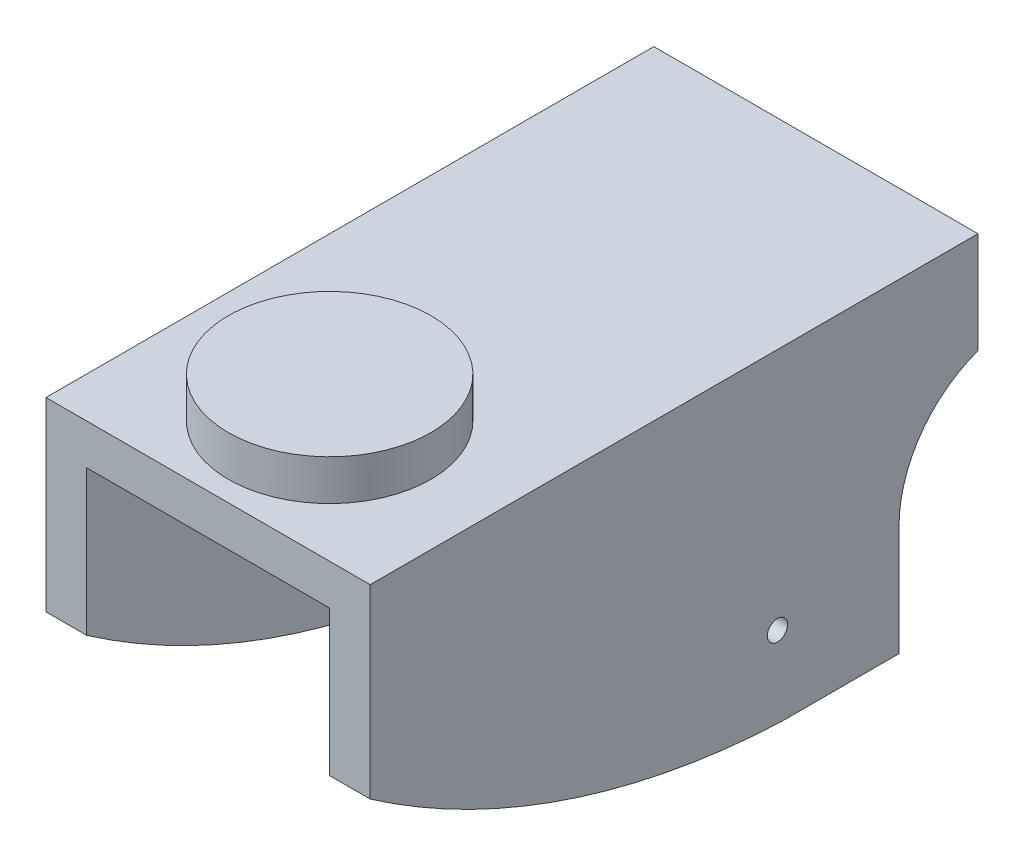
from build123d import *

# Parameters (mm, degrees)
BOSS_EXTRUDE1_DEPTH     = 20.32
SHELL1_T                = -2.54
SKETCH3_R               = 6.35
BOSS_EXTRUDE2_DEPTH     = 2.54
SKETCH5_R               = 0.635
CUT_EXTRUDE2_DEPTH      = 1
CUT_EXTRUDE2_DEPTH_BACK = 21.32


with BuildPart() as part:
    # Sketch2 → Boss-Extrude1 (new body)
    with BuildSketch(Plane(origin=(0, 0, 0), x_dir=(0, 0, -1), z_dir=(1, 0, 0))):
        with BuildLine():
            Line((0, 0), (38.1, 0))
            Line((38.1, 0), (38.1, -6.35))
            ThreePointArc((38.1, -6.35), (34.505388745, -9.09166098), (33.149673366, -13.404429327))
            Line((33.149673366, -13.404429327), (33.149673366, -20.32))
            Line((33.149673366, -20.32), (25.753107907, -20.32))
            ThreePointArc((25.753107907, -20.32), (12.259334003, -17.809647323), (0, -11.637732342))
            Line((0, -11.637732342), (0, 0))
        make_face()
    extrude(amount=BOSS_EXTRUDE1_DEPTH)

    # Shell1
    shell1_openings = [part.faces().sort_by_distance(p)[0] for p in [
        (10.16, -3.175, -38.1),
        (10.16, -9.484437822, -35.065112714),
        (10.16, -16.862214664, -33.149673366),
        (10.16, -20.32, -29.451390636),
        (10.16, -16.894256747, -12.567943978),
        (10.16, -5.818866171, 0),
    ]]
    offset(amount=SHELL1_T, openings=shell1_openings, kind=Kind.INTERSECTION)

    # Sketch3 → Boss-Extrude2 (add)
    with BuildSketch(Plane(origin=(0, 0, 0), x_dir=(1, 0, 0), z_dir=(0, 1, 0))):
        with Locations((10.16, 7.62)):
            Circle(SKETCH3_R)
    extrude(amount=BOSS_EXTRUDE2_DEPTH)

    # Sketch5 → Cut-Extrude2 (cut, two sides)
    with BuildSketch(Plane(origin=(20.32, 0, 0), x_dir=(0, 0, -1), z_dir=(1, 0, 0))) as cut_extrude2_sk:
        with Locations((25.529673366, -15.24)):
            Circle(SKETCH5_R)
    extrude(amount=CUT_EXTRUDE2_DEPTH, mode=Mode.SUBTRACT)
    extrude(cut_extrude2_sk.sketch, amount=-CUT_EXTRUDE2_DEPTH_BACK, mode=Mode.SUBTRACT)


solid = part.part
